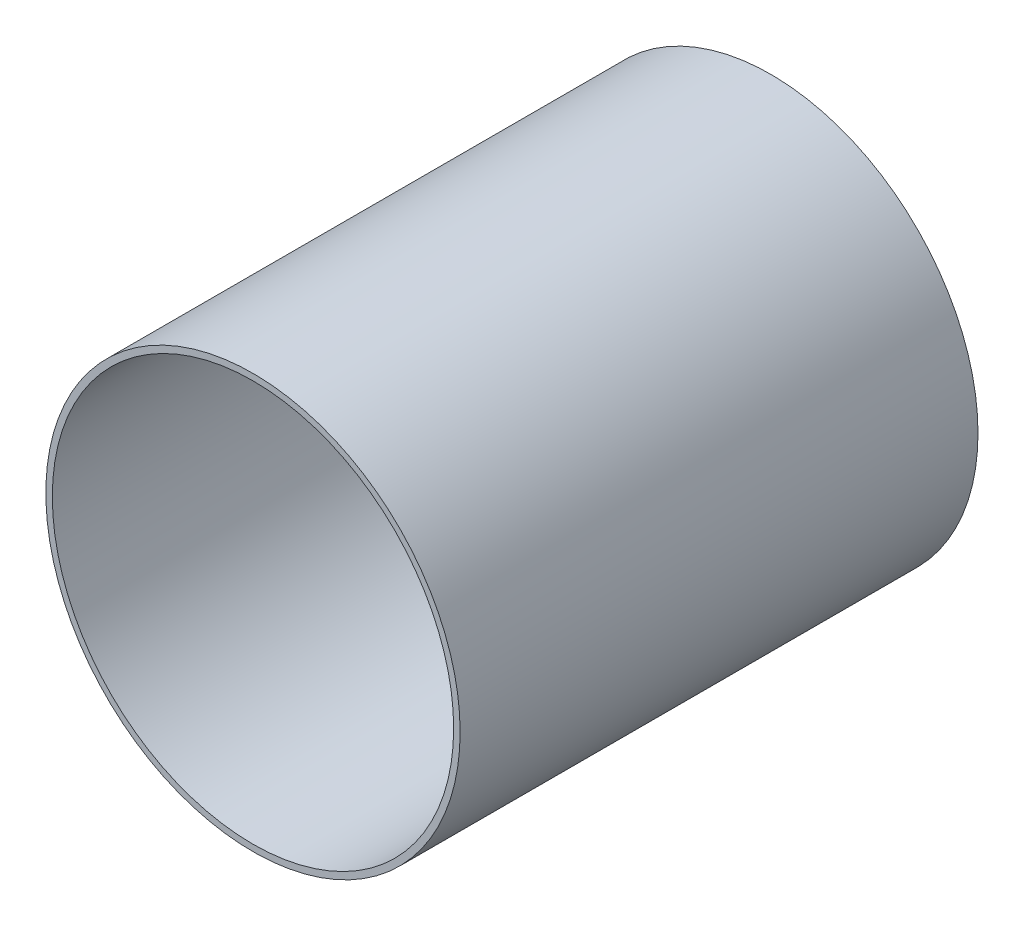
from build123d import *

# Parameters (mm, degrees)
ESQUISSE3_R             = 80
BOSS_EXTRU_2_DEPTH      = 200
ESQUISSE4_R             = 77.5
ENL_V_MAT_EXTRU_2_DEPTH = 195


with BuildPart() as part:
    # Esquisse3 → Boss.-Extru.2 (new body)
    with BuildSketch(Plane.XY):
        Circle(ESQUISSE3_R)
    extrude(amount=BOSS_EXTRU_2_DEPTH)

    # Esquisse4 → Enlèv. mat.-Extru.2 (cut)
    with BuildSketch(Plane.XY.offset(200)):
        Circle(ESQUISSE4_R)
    extrude(amount=-ENL_V_MAT_EXTRU_2_DEPTH, mode=Mode.SUBTRACT)


solid = part.part
